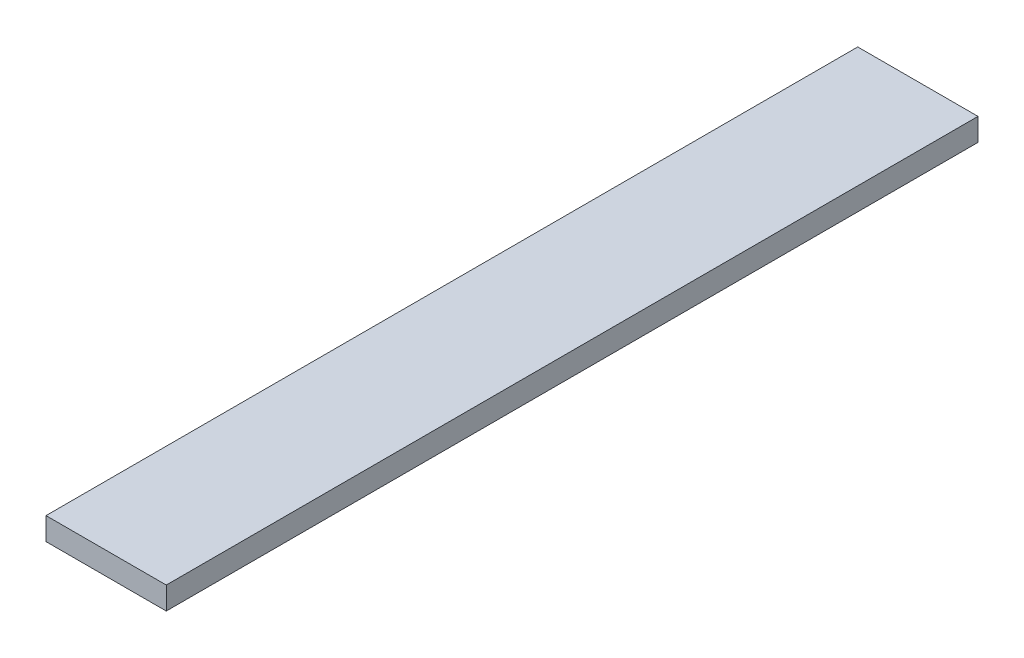
from build123d import *

# Parameters (mm, degrees)
SKETCH1_W           = 101.6
SKETCH1_H           = 685.8
BOSS_EXTRUDE1_DEPTH = 19.05


with BuildPart() as part:
    # Sketch1 → Boss-Extrude1 (new body)
    with BuildSketch(Plane(origin=(0, 0, 0), x_dir=(1, 0, 0), z_dir=(0, 1, 0))):
        Rectangle(SKETCH1_W, SKETCH1_H)
    extrude(amount=BOSS_EXTRUDE1_DEPTH)


solid = part.part
